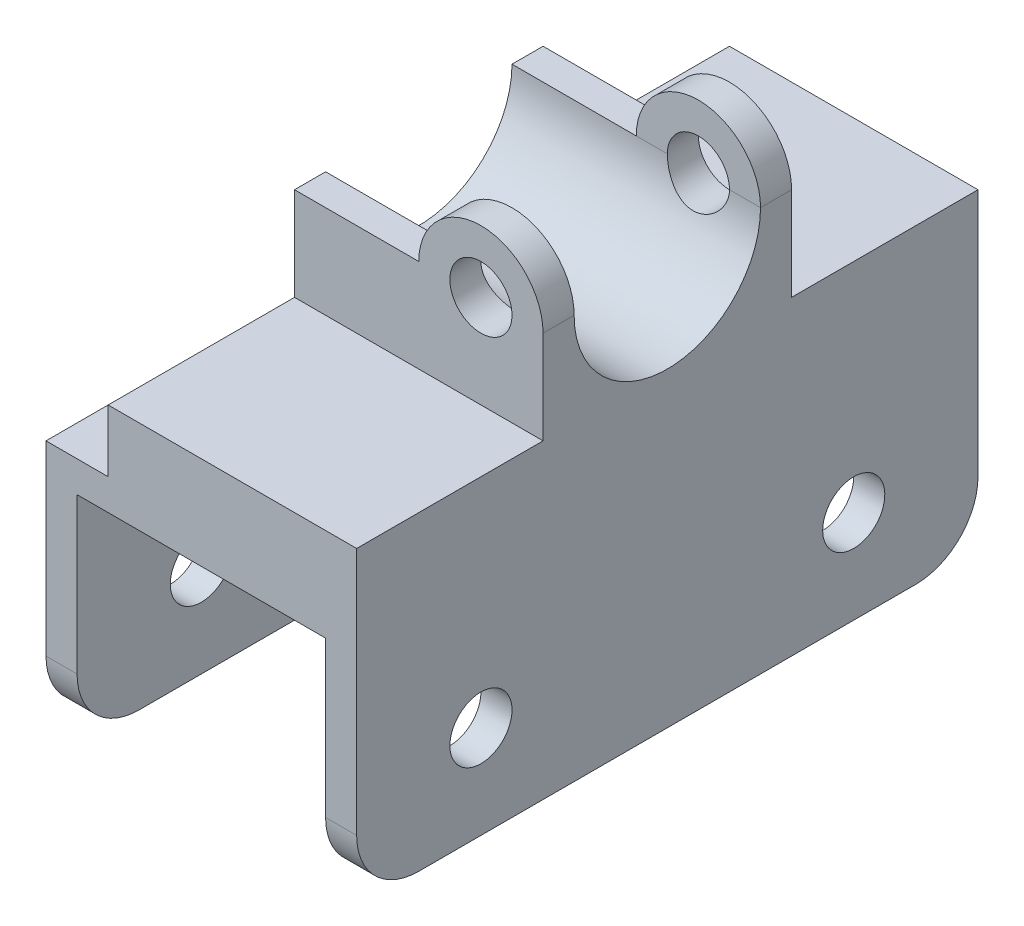
from build123d import *

# Parameters (mm, degrees)
SKETCH1_R               = 5
BOSS_EXTRUDE1_DEPTH     = 100
SKETCH2_R               = 5
SKETCH2_W               = 30
SKETCH2_H               = 25
CUT_EXTRUDE1_DEPTH      = 100
FILLET1_R               = 10
SKETCH4_W               = 40
SKETCH4_H               = 100
BOSS_EXTRUDE2_DEPTH     = 10
SKETCH5_W               = 10
SKETCH5_H               = 20
CUT_EXTRUDE2_DEPTH      = 101
CUT_EXTRUDE2_DEPTH_BACK = 1
SKETCH6_W               = 10
SKETCH6_H               = 5
CUT_EXTRUDE3_DEPTH      = 1
CUT_EXTRUDE3_DEPTH_BACK = 101


with BuildPart() as part:
    # Sketch1 → Boss-Extrude1 (new body)
    with BuildSketch(Plane.XY):
        with BuildLine():
            Line((50, 0), (50, 65))
            ThreePointArc((50, 65), (40, 75), (30, 65))
            Line((30, 65), (0, 65))
            Line((0, 65), (0, 0))
            Line((0, 0), (5, 0))
            Line((5, 0), (5, 45))
            Line((5, 45), (45, 45))
            Line((45, 45), (45, 0))
            Line((45, 0), (50, 0))
        make_face()
        with Locations((40, 65)):
            Circle(SKETCH1_R, mode=Mode.SUBTRACT)
    extrude(amount=BOSS_EXTRUDE1_DEPTH)

    # Sketch2 → Cut-Extrude1 (cut)
    with BuildSketch(Plane(origin=(50, 0, 0), x_dir=(0, 0, -1), z_dir=(1, 0, 0))):
        with Locations((-80, 15)):
            Circle(SKETCH2_R)
        with Locations((-20, 15)):
            Circle(SKETCH2_R)
        with BuildLine():
            Line((-65, 65), (-65, 75))
            Line((-65, 75), (-35, 75))
            Line((-35, 75), (-35, 65))
            ThreePointArc((-35, 65), (-50, 50), (-65, 65))
        make_face()
        with Locations((-85, 62.5)):
            Rectangle(SKETCH2_W, SKETCH2_H)
        with Locations((-15, 62.5)):
            Rectangle(SKETCH2_W, SKETCH2_H)
    extrude(amount=-CUT_EXTRUDE1_DEPTH, mode=Mode.SUBTRACT)

    # Fillet1
    fillet1_edges = [part.edges().sort_by_distance(p)[0] for p in [
        (47.5, 0, 0),
        (2.5, 0, 0),
        (2.5, 0, 100),
        (47.5, 0, 100),
    ]]
    fillet(fillet1_edges, radius=FILLET1_R)

    # Sketch4 → Boss-Extrude2 (add)
    with BuildSketch(Plane.XZ.offset(-45)):
        with Locations((25, 50)):
            Rectangle(SKETCH4_W, SKETCH4_H)
    extrude(amount=BOSS_EXTRUDE2_DEPTH)

    # Sketch5 → Cut-Extrude2 (cut, two sides)
    with BuildSketch(Plane.XY) as cut_extrude2_sk:
        with Locations((5, 55)):
            Rectangle(SKETCH5_W, SKETCH5_H)
    extrude(amount=CUT_EXTRUDE2_DEPTH, mode=Mode.SUBTRACT)
    extrude(cut_extrude2_sk.sketch, amount=-CUT_EXTRUDE2_DEPTH_BACK, mode=Mode.SUBTRACT)

    # Sketch6 → Cut-Extrude3 (cut, two sides)
    with BuildSketch(Plane.XY.offset(100)) as cut_extrude3_sk:
        with Locations((5, 42.5)):
            Rectangle(SKETCH6_W, SKETCH6_H)
    extrude(amount=CUT_EXTRUDE3_DEPTH, mode=Mode.SUBTRACT)
    extrude(cut_extrude3_sk.sketch, amount=-CUT_EXTRUDE3_DEPTH_BACK, mode=Mode.SUBTRACT)


solid = part.part
